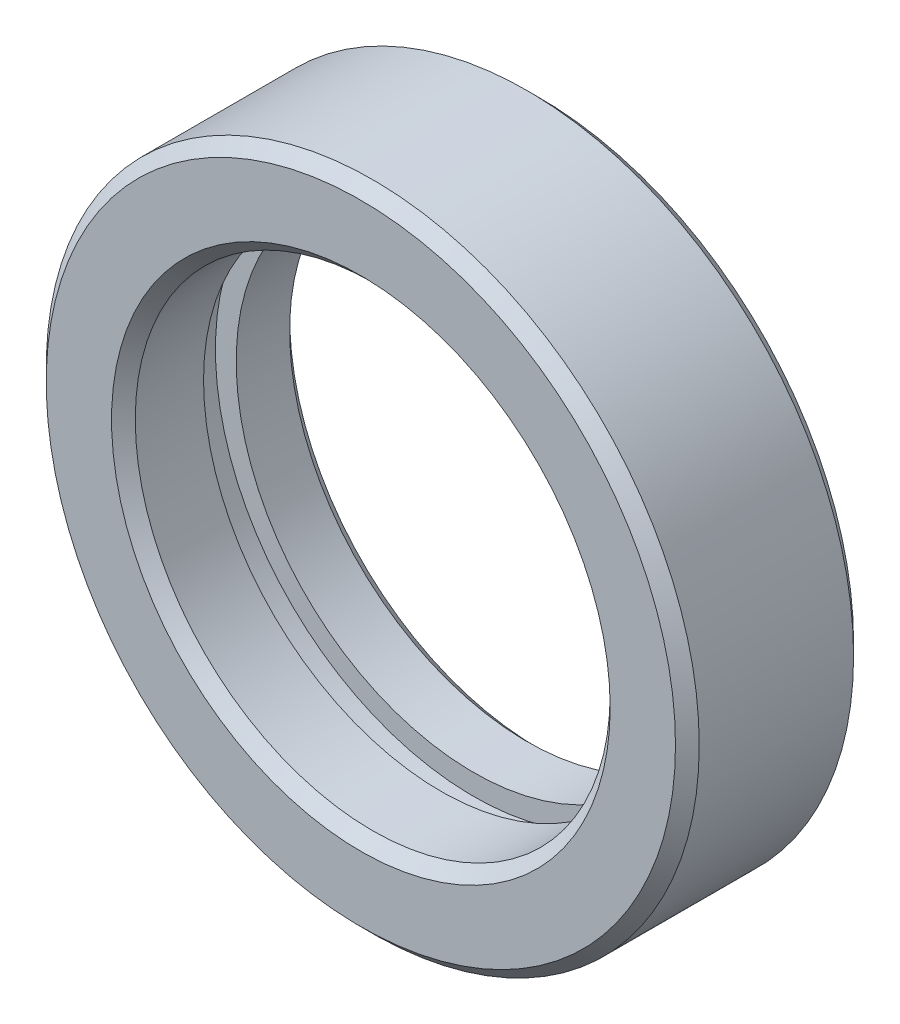
from build123d import *

# Parameters (mm, degrees)
SKETCH1_R           = 55
SKETCH1_R_2         = 40
BOSS_EXTRUDE1_DEPTH = 15
CHAMFER1_SIZE       = 2
SKETCH2_W           = 7.914202957
SKETCH2_H           = 5.5


with BuildPart() as part:
    # Sketch1 → Boss-Extrude1 (new body, symmetric)
    with BuildSketch(Plane.XY):
        Circle(SKETCH1_R)
        Circle(SKETCH1_R_2, mode=Mode.SUBTRACT)
    extrude(amount=BOSS_EXTRUDE1_DEPTH, both=True)

    # Chamfer1
    chamfer1_edges = [part.edges().sort_by_distance(p)[0] for p in [
        (-55, 0, -15),
        (-55, 0, 15),
        (-40, 0, -15),
        (-40, 0, 15),
    ]]
    chamfer(chamfer1_edges, length=CHAMFER1_SIZE)

    # Sketch2 → Cut-Revolve1 (revolve, cut)
    with BuildSketch(Plane(origin=(0, 0, 0), x_dir=(1, 0, 0), z_dir=(0, 1, 0))):
        with Locations((-39.542898521, 1.25)):
            Rectangle(SKETCH2_W, SKETCH2_H)
    revolve(axis=Axis((0, 0, 0), (0, 0, -1)), mode=Mode.SUBTRACT)


solid = part.part
